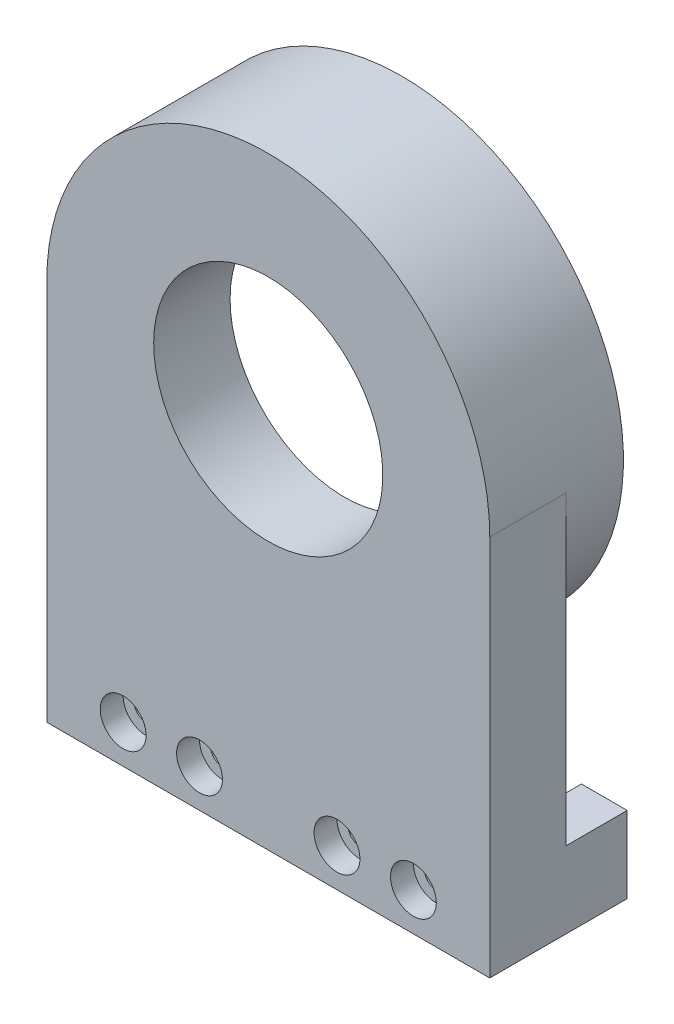
from build123d import *

# Parameters (mm, degrees)
SKETCH_1_W          = 58
SKETCH_1_H          = 50
EXTRUDE_1_DEPTH     = 10
SKETCH_2_R          = 29
SKETCH_2_R_2        = 26.1
EXTRUDE_2_DEPTH     = 7.5
SKETCH_3_R          = 26.1
SKETCH_3_R_2        = 24
EXTRUDE_3_DEPTH     = 0.5
SKETCH_4_W          = 6
SKETCH_4_H          = 5
EXTRUDE_4_DEPTH     = 8
CUT_EXTRUDE_1_REACH = 12
SKETCH_5_R          = 1.55
SKETCH_6_R          = 3
CUT_EXTRUDE_2_DEPTH = 3
SKETCH_7_R          = 15
CUT_EXTRUDE_3_DEPTH = 11


with BuildPart() as part:
    # 草图1 → 凸台-拉伸1 (new body)
    with BuildSketch(Plane.XY):
        with BuildLine():
            ThreePointArc((-29, 25), (0, 54), (29, 25))
            Line((29, 25), (-29, 25))
        make_face()
        Rectangle(SKETCH_1_W, SKETCH_1_H)
    extrude(amount=EXTRUDE_1_DEPTH)

    # 草图2 → 凸台-拉伸2 (add)
    with BuildSketch(Plane(origin=(0, 0, 0), x_dir=(-1, 0, 0), z_dir=(0, 0, -1))):
        with Locations((0, 25)):
            Circle(SKETCH_2_R)
        with Locations((0, 25)):
            Circle(SKETCH_2_R_2, mode=Mode.SUBTRACT)
    extrude(amount=EXTRUDE_2_DEPTH)

    # 草图3 → 凸台-拉伸3 (add)
    with BuildSketch(Plane(origin=(0, 0, 0), x_dir=(-1, 0, 0), z_dir=(0, 0, -1))):
        with Locations((0, 25)):
            Circle(SKETCH_3_R)
        with Locations((0, 25)):
            Circle(SKETCH_3_R_2, mode=Mode.SUBTRACT)
    extrude(amount=EXTRUDE_3_DEPTH)

    # 草图4 → 凸台-拉伸4 (add)
    with BuildSketch(Plane(origin=(0, 0, 0), x_dir=(-1, 0, 0), z_dir=(0, 0, -1))):
        with Locations((-26, -17.5)):
            Rectangle(SKETCH_4_W, SKETCH_4_H)
        with Locations((-26, -22.5)):
            Rectangle(SKETCH_4_W, SKETCH_4_H)
        with Locations((26, -17.5)):
            Rectangle(SKETCH_4_W, SKETCH_4_H)
        with Locations((26, -22.5)):
            Rectangle(SKETCH_4_W, SKETCH_4_H)
    extrude(amount=EXTRUDE_4_DEPTH)

    # 草图5 → 切除-拉伸1 (cut, up to next)
    with BuildSketch(Plane(origin=(0, 0, 0), x_dir=(-1, 0, 0), z_dir=(0, 0, -1)), mode=Mode.PRIVATE) as cut_extrude_1_sk1:
        with Locations((-19, -20)):
            Circle(SKETCH_5_R)
    cut_extrude_1_tool1 = extrude(cut_extrude_1_sk1.sketch, amount=-CUT_EXTRUDE_1_REACH, mode=Mode.PRIVATE) & part.part
    add(cut_extrude_1_tool1.solids().sort_by_distance((19, -20, 0))[0], mode=Mode.SUBTRACT)
    # 草图5 → 切除-拉伸1 (cut, up to next)
    with BuildSketch(Plane(origin=(0, 0, 0), x_dir=(-1, 0, 0), z_dir=(0, 0, -1)), mode=Mode.PRIVATE) as cut_extrude_1_sk2:
        with Locations((-9, -20)):
            Circle(SKETCH_5_R)
    cut_extrude_1_tool2 = extrude(cut_extrude_1_sk2.sketch, amount=-CUT_EXTRUDE_1_REACH, mode=Mode.PRIVATE) & part.part
    add(cut_extrude_1_tool2.solids().sort_by_distance((9, -20, 0))[0], mode=Mode.SUBTRACT)
    # 草图5 → 切除-拉伸1 (cut, up to next)
    with BuildSketch(Plane(origin=(0, 0, 0), x_dir=(-1, 0, 0), z_dir=(0, 0, -1)), mode=Mode.PRIVATE) as cut_extrude_1_sk3:
        with Locations((9, -20)):
            Circle(SKETCH_5_R)
    cut_extrude_1_tool3 = extrude(cut_extrude_1_sk3.sketch, amount=-CUT_EXTRUDE_1_REACH, mode=Mode.PRIVATE) & part.part
    add(cut_extrude_1_tool3.solids().sort_by_distance((-9, -20, 0))[0], mode=Mode.SUBTRACT)
    # 草图5 → 切除-拉伸1 (cut, up to next)
    with BuildSketch(Plane(origin=(0, 0, 0), x_dir=(-1, 0, 0), z_dir=(0, 0, -1)), mode=Mode.PRIVATE) as cut_extrude_1_sk4:
        with Locations((19, -20)):
            Circle(SKETCH_5_R)
    cut_extrude_1_tool4 = extrude(cut_extrude_1_sk4.sketch, amount=-CUT_EXTRUDE_1_REACH, mode=Mode.PRIVATE) & part.part
    add(cut_extrude_1_tool4.solids().sort_by_distance((-19, -20, 0))[0], mode=Mode.SUBTRACT)

    # 草图6 → 切除-拉伸2 (cut)
    with BuildSketch(Plane.XY.offset(10)):
        with Locations((19, -20)):
            Circle(SKETCH_6_R)
        with Locations((9, -20)):
            Circle(SKETCH_6_R)
        with Locations((-9, -20)):
            Circle(SKETCH_6_R)
        with Locations((-19, -20)):
            Circle(SKETCH_6_R)
    extrude(amount=-CUT_EXTRUDE_2_DEPTH, mode=Mode.SUBTRACT)

    # 草图7 → 切除-拉伸3 (cut, through all)
    with BuildSketch(Plane(origin=(0, 0, 0), x_dir=(-1, 0, 0), z_dir=(0, 0, -1))):
        with Locations((0, 25)):
            Circle(SKETCH_7_R)
    extrude(amount=-CUT_EXTRUDE_3_DEPTH, mode=Mode.SUBTRACT)


solid = part.part
